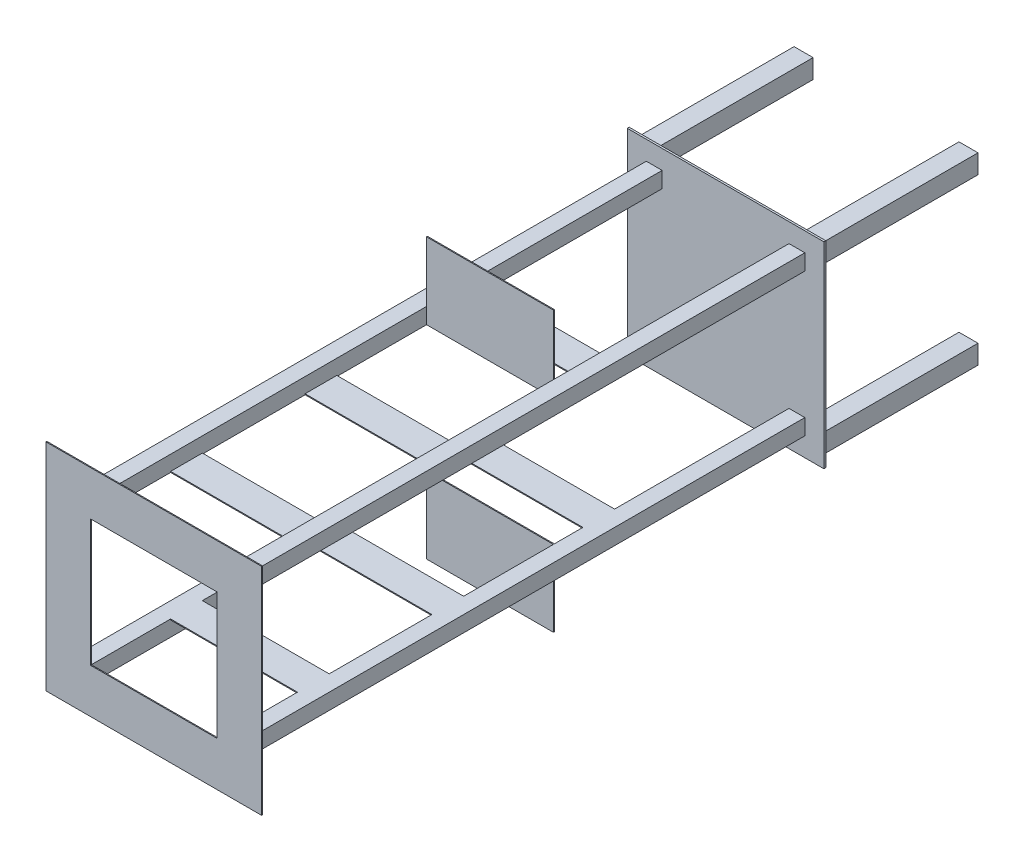
from build123d import *

# Parameters (mm, degrees)
SKETCH_1_W        = 30
SKETCH_1_H        = 30
SKETCH_1_W_2      = 26
SKETCH_1_H_2      = 26
EXTRUDE_1_DEPTH   = 250
EXTRUDE_1_2_DEPTH = 250
EXTRUDE_1_3_DEPTH = 250
EXTRUDE_1_4_DEPTH = 250
SKETCH_2_W        = 310
SKETCH_2_H        = 310
EXTRUDE_2_DEPTH   = 3
SKETCH_5_W        = 25
SKETCH_5_H        = 25
SKETCH_5_W_2      = 22
SKETCH_5_H_2      = 22
EXTRUDE_3_DEPTH   = 900
SKETCH_6_W        = 340
SKETCH_6_H        = 340
SKETCH_6_W_2      = 200
SKETCH_6_H_2      = 200
EXTRUDE_4_DEPTH   = 1.5
SKETCH_7_W        = 200
SKETCH_7_H        = 120
EXTRUDE_5_DEPTH   = 1.5
SKETCH_8_W        = 200
SKETCH_8_H        = 1.5
EXTRUDE_6_DEPTH   = 25
SKETCH_9_W        = 200
SKETCH_9_H        = 1.5
EXTRUDE_7_DEPTH   = 25
SKETCH_11_W       = 200
SKETCH_11_H       = 1.5
EXTRUDE_8_DEPTH   = 25


with BuildPart() as part:
    # 草圖1 → 填料-伸長1 (new body)
    with BuildSketch(Plane.XY):
        with Locations((-83.068744212, 102.787427317)):
            Rectangle(SKETCH_1_W, SKETCH_1_H)
        with Locations((-83.068744212, 102.787427317)):
            Rectangle(SKETCH_1_W_2, SKETCH_1_H_2, mode=Mode.SUBTRACT)
    extrude(amount=EXTRUDE_1_DEPTH)



with BuildPart() as body_2:
    # 草圖1 → Extrude 1 2 (new body)
    with BuildSketch(Plane.XY):
        with Locations((176.931255788, 102.787427317)):
            Rectangle(SKETCH_1_W, SKETCH_1_H)
        with Locations((176.931255788, 102.787427317)):
            Rectangle(SKETCH_1_W_2, SKETCH_1_H_2, mode=Mode.SUBTRACT)
    extrude(amount=EXTRUDE_1_2_DEPTH)


with BuildPart() as body_3:
    # 草圖1 → Extrude 1 3 (new body)
    with BuildSketch(Plane.XY):
        with Locations((-83.068744212, -157.212572683)):
            Rectangle(SKETCH_1_W, SKETCH_1_H)
        with Locations((-83.068744212, -157.212572683)):
            Rectangle(SKETCH_1_W_2, SKETCH_1_H_2, mode=Mode.SUBTRACT)
    extrude(amount=EXTRUDE_1_3_DEPTH)


with BuildPart() as body_4:
    # 草圖1 → Extrude 1 4 (new body)
    with BuildSketch(Plane.XY):
        with Locations((176.931255788, -157.212572683)):
            Rectangle(SKETCH_1_W, SKETCH_1_H)
        with Locations((176.931255788, -157.212572683)):
            Rectangle(SKETCH_1_W_2, SKETCH_1_H_2, mode=Mode.SUBTRACT)
    extrude(amount=EXTRUDE_1_4_DEPTH)


with BuildPart() as part_1:
    add(part.part)

    add(body_2.part)  # 填料-伸長2 merges body 2

    add(body_3.part)  # 填料-伸長2 merges body 3

    add(body_4.part)  # 填料-伸長2 merges body 4
    # 草圖2 → 填料-伸長2 (add)
    with BuildSketch(Plane.XY.offset(250)):
        with Locations((46.931255788, -27.212572683)):
            Rectangle(SKETCH_2_W, SKETCH_2_H)
    extrude(amount=EXTRUDE_2_DEPTH)

    # 草圖5 → 填料-伸長3 (add)
    with BuildSketch(Plane.XY.offset(253)):
        with Locations((-65.568744212, 85.287427317)):
            Rectangle(SKETCH_5_W, SKETCH_5_H)
        with Locations((-65.568744212, 85.287427317)):
            Rectangle(SKETCH_5_W_2, SKETCH_5_H_2, mode=Mode.SUBTRACT)
        with Locations((-65.568744212, -139.712572683)):
            Rectangle(SKETCH_5_W, SKETCH_5_H)
        with Locations((-65.568744212, -139.712572683)):
            Rectangle(SKETCH_5_W_2, SKETCH_5_H_2, mode=Mode.SUBTRACT)
        with Locations((159.431255788, -139.712572683)):
            Rectangle(SKETCH_5_W, SKETCH_5_H)
        with Locations((159.431255788, -139.712572683)):
            Rectangle(SKETCH_5_W_2, SKETCH_5_H_2, mode=Mode.SUBTRACT)
        with Locations((159.431255788, 85.287427317)):
            Rectangle(SKETCH_5_W, SKETCH_5_H)
        with Locations((159.431255788, 85.287427317)):
            Rectangle(SKETCH_5_W_2, SKETCH_5_H_2, mode=Mode.SUBTRACT)
    extrude(amount=EXTRUDE_3_DEPTH)

    # 草圖6 → 填料-伸長4 (add)
    with BuildSketch(Plane.XY.offset(1153)):
        with Locations((46.931255788, -27.212572683)):
            Rectangle(SKETCH_6_W, SKETCH_6_H)
        with Locations((46.931255788, -27.212572683)):
            Rectangle(SKETCH_6_W_2, SKETCH_6_H_2, mode=Mode.SUBTRACT)
    extrude(amount=EXTRUDE_4_DEPTH)

    # 草圖7 → 填料-伸長5 (add)
    with BuildSketch(Plane.XY.offset(623)):
        with Locations((46.931255788, 132.787427317)):
            Rectangle(SKETCH_7_W, SKETCH_7_H)
        with Locations((46.931255788, -187.212572683)):
            Rectangle(SKETCH_7_W, SKETCH_7_H)
    extrude(amount=EXTRUDE_5_DEPTH)

    # 草圖8 → 填料-伸長6 (add, symmetric)
    with BuildSketch(Plane(origin=(0, 0, 1003), x_dir=(-1, 0, 0), z_dir=(0, 0, -1))):
        with Locations((-46.931255788, 73.537427317)):
            Rectangle(SKETCH_8_W, SKETCH_8_H)
        with Locations((-46.931255788, -127.962572683)):
            Rectangle(SKETCH_8_W, SKETCH_8_H)
    extrude(amount=EXTRUDE_6_DEPTH, both=True)

    # 草圖9 → 填料-伸長7 (add, symmetric)
    with BuildSketch(Plane(origin=(0, 0, 791), x_dir=(-1, 0, 0), z_dir=(0, 0, -1))):
        with Locations((-46.931255788, 73.537427317)):
            Rectangle(SKETCH_9_W, SKETCH_9_H)
        with Locations((-46.931255788, -127.962572683)):
            Rectangle(SKETCH_9_W, SKETCH_9_H)
    extrude(amount=EXTRUDE_7_DEPTH, both=True)

    # 草圖11 → 填料-伸長8 (add, symmetric)
    with BuildSketch(Plane(origin=(0, 0, 553), x_dir=(-1, 0, 0), z_dir=(0, 0, -1))):
        with Locations((-46.931255788, -127.962572683)):
            Rectangle(SKETCH_11_W, SKETCH_11_H)
        with Locations((-46.931255788, 73.537427317)):
            Rectangle(SKETCH_11_W, SKETCH_11_H)
    extrude(amount=EXTRUDE_8_DEPTH, both=True)


solid = part_1.part
